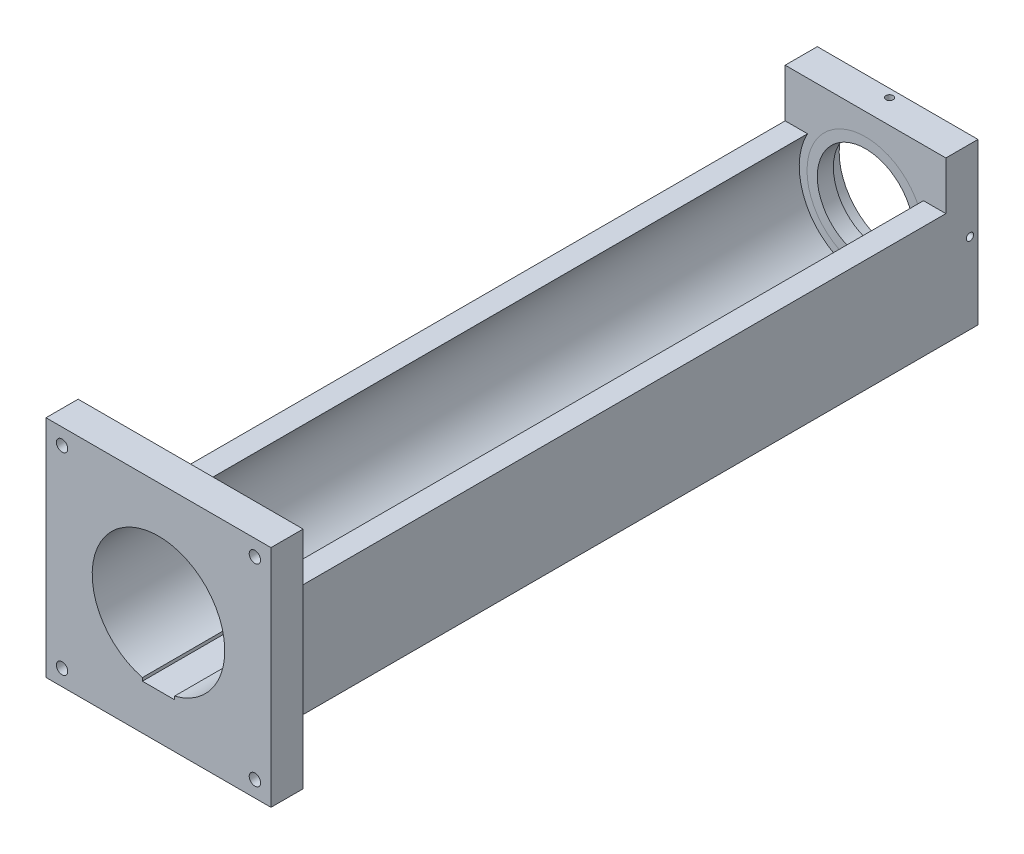
from build123d import *

# Parameters (mm, degrees)
SKETCH2_W                                     = 63.5
SKETCH2_H                                     = 63.5
SKETCH2_R                                     = 26.19375
BOSS_EXTRUDE1_DEPTH                           = 279.4
SKETCH3_W                                     = 88.9
SKETCH3_H                                     = 88.9
SKETCH3_R                                     = 26.19375
BOSS_EXTRUDE2_DEPTH                           = 12.7
SKETCH4_W                                     = 63.5
SKETCH4_H                                     = 63.5
SKETCH4_R                                     = 23.114
BOSS_EXTRUDE3_DEPTH                           = 12.7
SKETCH5_R                                     = 23.114
SKETCH5_R_2                                   = 19.05
BOSS_EXTRUDE4_DEPTH                           = 6.35
SKETCH7_W                                     = 266.7
SKETCH7_H                                     = 19.05
CUT_EXTRUDE2_DEPTH                            = 77.2
SKETCH8_W                                     = 1.4351
SKETCH8_H                                     = 76.2
SKETCH10_W                                    = 1.4351
SKETCH10_H                                    = 76.2
CSK_FOR_8_FLAT_HEAD_MACHINE_SCREW1_AT_2_COUNT = 2
CSK_FOR_8_FLAT_HEAD_MACHINE_SCREW1_AT_2_PITCH = 76.2
CSK_FOR_8_FLAT_HEAD_MACHINE_SCREW1_AT_3_COUNT = 2
CSK_FOR_8_FLAT_HEAD_MACHINE_SCREW1_AT_3_PITCH = 107.763073453
CSK_FOR_8_FLAT_HEAD_MACHINE_SCREW1_AT_4_COUNT = 2
CSK_FOR_8_FLAT_HEAD_MACHINE_SCREW1_AT_4_PITCH = 76.2
SKETCH16_W                                    = 12.7
SKETCH16_H                                    = 2.6035
CUT_EXTRUDE3_DEPTH                            = 279.4
F_1_4_20_TAPPED_HOLE1_AT_2_COUNT              = 2
F_1_4_20_TAPPED_HOLE1_AT_2_PITCH              = 169.439133614


with BuildPart() as part:
    # Sketch2 → Boss-Extrude1 (new body)
    with BuildSketch(Plane.XY):
        with Locations((31.75, 31.75)):
            Rectangle(SKETCH2_W, SKETCH2_H)
        with Locations((31.75, 31.75)):
            Circle(SKETCH2_R, mode=Mode.SUBTRACT)
    extrude(amount=BOSS_EXTRUDE1_DEPTH)

    # Sketch3 → Boss-Extrude2 (add)
    with BuildSketch(Plane.XY.offset(279.4)):
        with Locations((31.75, 31.75)):
            Rectangle(SKETCH3_W, SKETCH3_H)
        with Locations((31.75, 31.75)):
            Circle(SKETCH3_R, mode=Mode.SUBTRACT)
    extrude(amount=-BOSS_EXTRUDE2_DEPTH)

    # Sketch4 → Boss-Extrude3 (add)
    with BuildSketch(Plane(origin=(0, 0, 0), x_dir=(-1, 0, 0), z_dir=(0, 0, -1))):
        with Locations((-31.75, 31.75)):
            Rectangle(SKETCH4_W, SKETCH4_H)
        with Locations((-31.75, 31.75)):
            Circle(SKETCH4_R, mode=Mode.SUBTRACT)
    extrude(amount=BOSS_EXTRUDE3_DEPTH)

    # Sketch7 → Cut-Extrude2 (cut, through all)
    with BuildSketch(Plane(origin=(63.5, 0, 0), x_dir=(0, 0, -1), z_dir=(1, 0, 0))):
        with Locations((-133.35, 53.975)):
            Rectangle(SKETCH7_W, SKETCH7_H)
    extrude(amount=-CUT_EXTRUDE2_DEPTH, mode=Mode.SUBTRACT)

    # Sketch8 → #6-40 Tapped Hole1 (revolve, cut)
    with BuildSketch(Plane(origin=(63.5, 31.75, -9.525), x_dir=(0, 0, -1), z_dir=(0, 1, 0))):
        with Locations((0.71755, 38.1)):
            Rectangle(SKETCH8_W, SKETCH8_H)
    revolve(axis=Axis((69.85, 31.75, -9.525), (-1, 0, 0)), mode=Mode.SUBTRACT)

    # Sketch10 → #6-40 Tapped Hole2 (revolve, cut)
    with BuildSketch(Plane(origin=(31.75, 63.5, -9.525), x_dir=(0, 0, 1), z_dir=(1, 0, 0))):
        with Locations((0.71755, 38.1)):
            Rectangle(SKETCH10_W, SKETCH10_H)
    revolve(axis=Axis((31.75, 69.85, -9.525), (0, -1, 0)), mode=Mode.SUBTRACT)

    # Sketch12 → CSK for #8 Flat Head Machine Screw1 (revolve, cut)
    with BuildSketch(Plane(origin=(69.85, 69.85, 266.7), x_dir=(0, 1, 0), z_dir=(1, 0, 0))):
        Polygon((0, 0), (0, 12.7), (2.2479, 12.7), (2.2479, 2.26450021), (4.2164, 0), align=None)
    csk_for_8_flat_head_machine_screw1 = revolve(axis=Axis((69.85, 69.85, 260.35), (0, 0, 1)), mode=Mode.SUBTRACT)

    # CSK for #8 Flat Head Machine Screw1 at 2: CSK for #8 Flat Head Machine Screw1 ×2
    with Locations(*[(-i * CSK_FOR_8_FLAT_HEAD_MACHINE_SCREW1_AT_2_PITCH, 0, 0) for i in range(1, CSK_FOR_8_FLAT_HEAD_MACHINE_SCREW1_AT_2_COUNT)]):
        add(csk_for_8_flat_head_machine_screw1, mode=Mode.SUBTRACT)

    # CSK for #8 Flat Head Machine Screw1 at 3: CSK for #8 Flat Head Machine Screw1 ×2
    with Locations(*[Vector(-0.707106781, -0.707106781, 0) * (i * CSK_FOR_8_FLAT_HEAD_MACHINE_SCREW1_AT_3_PITCH) for i in range(1, CSK_FOR_8_FLAT_HEAD_MACHINE_SCREW1_AT_3_COUNT)]):
        add(csk_for_8_flat_head_machine_screw1, mode=Mode.SUBTRACT)

    # CSK for #8 Flat Head Machine Screw1 at 4: CSK for #8 Flat Head Machine Screw1 ×2
    with Locations(*[(0, -i * CSK_FOR_8_FLAT_HEAD_MACHINE_SCREW1_AT_4_PITCH, 0) for i in range(1, CSK_FOR_8_FLAT_HEAD_MACHINE_SCREW1_AT_4_COUNT)]):
        add(csk_for_8_flat_head_machine_screw1, mode=Mode.SUBTRACT)

    # Sketch16 → Cut-Extrude3 (cut)
    with BuildSketch(Plane.XY.offset(279.4)):
        with Locations((31.75, 6.38175)):
            Rectangle(SKETCH16_W, SKETCH16_H)
    extrude(amount=-CUT_EXTRUDE3_DEPTH, mode=Mode.SUBTRACT)

    # Sketch19 → 1/4-20 Tapped Hole1 (revolve, cut)
    with BuildSketch(Plane(origin=(50.8, 0, 50.8), x_dir=(0, 0, -1), z_dir=(1, 0, 0))):
        Polygon((0, 0), (0, 11.693816902), (2.5527, 10.16), (2.5527, 0), align=None)
    f_1_4_20_tapped_hole1 = revolve(axis=Axis((50.8, -6.35, 50.8), (0, 1, 0)), mode=Mode.SUBTRACT)

    # 1/4-20 Tapped Hole1 at 2: 1/4-20 Tapped Hole1 ×2
    with Locations(*[Vector(-0.224859507, 0, 0.974391196) * (i * F_1_4_20_TAPPED_HOLE1_AT_2_PITCH) for i in range(1, F_1_4_20_TAPPED_HOLE1_AT_2_COUNT)]):
        add(f_1_4_20_tapped_hole1, mode=Mode.SUBTRACT)


with BuildPart() as body_2:
    # Sketch5 → Boss-Extrude4 (new body)
    with BuildSketch(Plane(origin=(0, 0, -6.35), x_dir=(-1, 0, 0), z_dir=(0, 0, -1))):
        with Locations((-31.75, 31.75)):
            Circle(SKETCH5_R)
        with Locations((-31.75, 31.75)):
            Circle(SKETCH5_R_2, mode=Mode.SUBTRACT)
    extrude(amount=-BOSS_EXTRUDE4_DEPTH)


solid = Compound([part.part, body_2.part])
